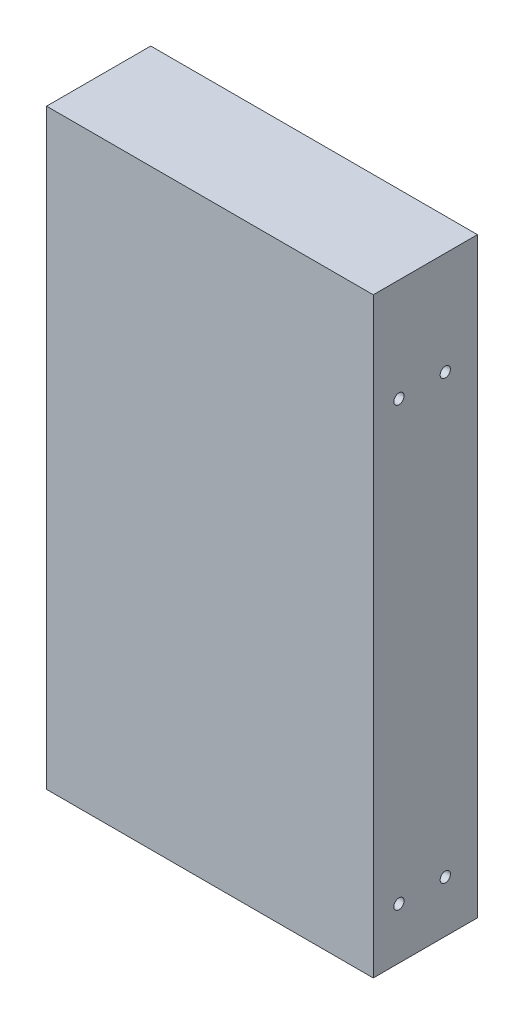
from build123d import *

# Parameters (mm, degrees)
CROQUIS1_W              = 127
CROQUIS1_H              = 230
SALIENTE_EXTRUIR2_DEPTH = 40.5
CROQUIS3_R              = 2
CORTAR_EXTRUIR1_DEPTH   = 10


with BuildPart() as part:
    # Croquis1 → Saliente-Extruir2 (new body)
    with BuildSketch(Plane.XY):
        with Locations((-63.5, 115)):
            Rectangle(CROQUIS1_W, CROQUIS1_H)
    extrude(amount=SALIENTE_EXTRUIR2_DEPTH)

    # Croquis3 → Cortar-Extruir1 (cut)
    with BuildSketch(Plane(origin=(0, 0, 0), x_dir=(0, 0, -1), z_dir=(1, 0, 0))):
        with Locations((-12.5, 190)):
            Circle(CROQUIS3_R)
        with Locations((-12.5, 20)):
            Circle(CROQUIS3_R)
        with Locations((-30.5, 190)):
            Circle(CROQUIS3_R)
        with Locations((-30.5, 20)):
            Circle(CROQUIS3_R)
    extrude(amount=-CORTAR_EXTRUIR1_DEPTH, mode=Mode.SUBTRACT)


solid = part.part
